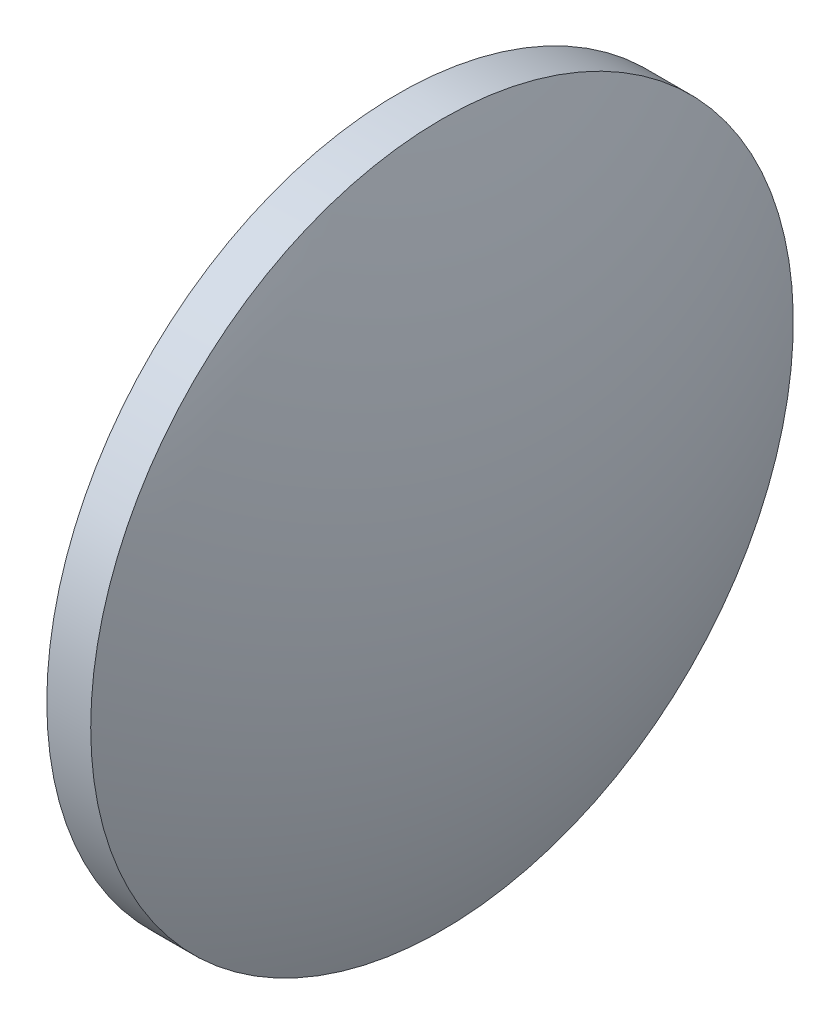
from build123d import *


with BuildPart() as part:
    # 草图1 → 旋转1 (revolve)
    with BuildSketch(Plane.XY):
        with BuildLine():
            Line((540.463306299, 183.981187911), (540.463306299, 203.981187911))
            Line((540.463306299, 203.981187911), (542.963306299, 203.981187911))
            ThreePointArc((542.963306299, 203.981187911), (545.975782097, 194.182179284), (546.993306299, 183.981187911))
            Line((546.993306299, 183.981187911), (540.463306299, 183.981187911))
        make_face()
    revolve(axis=Axis((530.956808979, 183.981187911, 0), (1, 0, 0)))


solid = part.part
